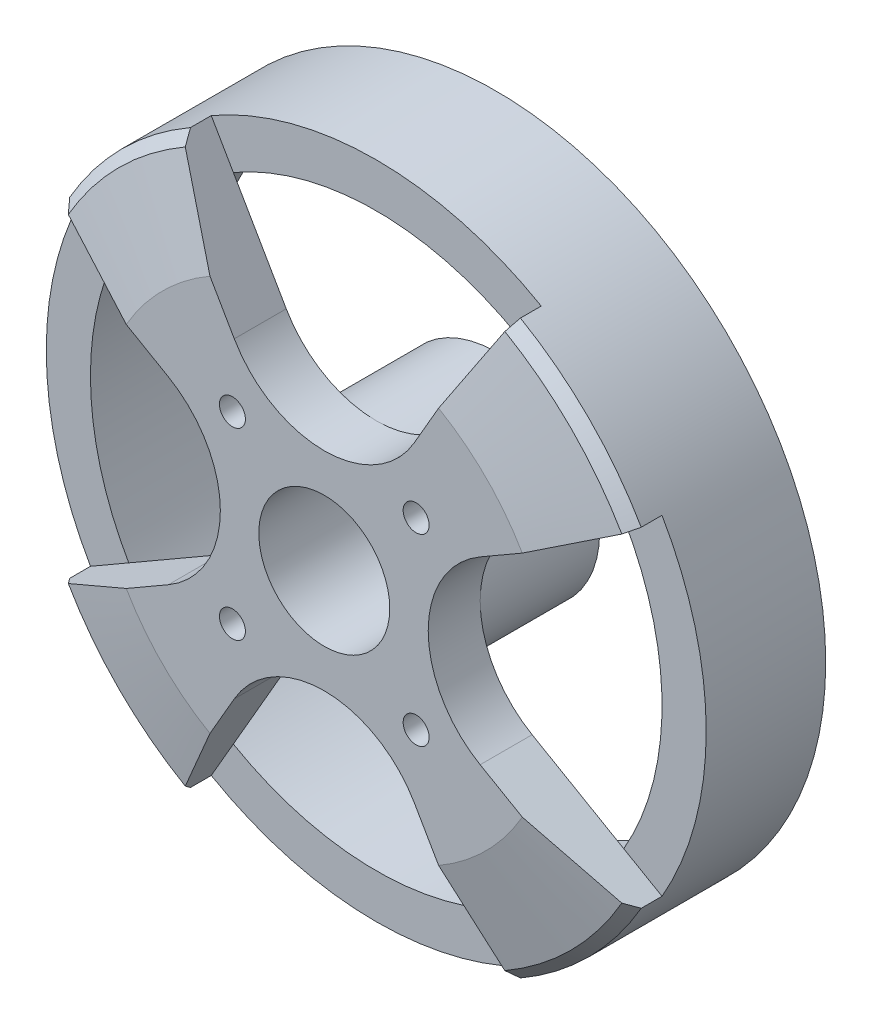
from build123d import *

# Parameters (mm, degrees)
SKETCH_1_R          = 31.75
EXTRUDE_1_DEPTH     = 14.5
CHAMFER_1_SIZE      = 1
SKETCH_3_R          = 30.75
SKETCH_2_R          = 22
SKETCH_4_R          = 6.3
CUT_EXTRUDE_1_DEPTH = 48.836962696
CUT_EXTRUDE_2_DEPTH = 5
SKETCH_6_R          = 27.5
CUT_EXTRUDE_3_DEPTH = 11.5
M3X0_51_D           = 2.5
SKETCH_11_R         = 10
SKETCH_11_R_2       = 6.3
EXTRUDE_2_DEPTH     = 11.5


with BuildPart() as part:
    # Эскиз1 → Бобышка-Вытянуть1 (new body)
    with BuildSketch(Plane.XY):
        with Locations(Location((0, 0, 0), (0, 0, 180))):
            Circle(SKETCH_1_R)
    extrude(amount=EXTRUDE_1_DEPTH)

    # Фаска1
    chamfer_1_edges = [part.edges().sort_by_distance(p)[0] for p in [
        (31.75, 0, 14.5),
    ]]
    chamfer(chamfer_1_edges, length=CHAMFER_1_SIZE)

    # Эскиз3 → По сечениям3 section 0
    with BuildSketch(Plane.XY.offset(14.5)):
        Circle(SKETCH_3_R)
    # Эскиз2 → По сечениям3 section 1
    with BuildSketch(Plane.XY.offset(16.5)):
        Circle(SKETCH_2_R)
    loft()

    # Эскиз4 → Вырез-Вытянуть1 (cut, through all)
    with BuildSketch(Plane.XY.offset(16.5)):
        Circle(SKETCH_4_R)
    extrude(amount=-CUT_EXTRUDE_1_DEPTH, mode=Mode.SUBTRACT)

    # Эскиз5 → Вырез-Вытянуть2 (cut)
    with BuildSketch(Plane.XY.offset(16.5)):
        with BuildLine():
            Line((-8.660254038, 15), (-15.875, 27.49630657))
            ThreePointArc((-15.875, 27.49630657), (0, 31.75), (15.875, 27.49630657))
            Line((15.875, 27.49630657), (8.660254038, 15))
            ThreePointArc((8.660254038, 15), (0, 10), (-8.660254038, 15))
        make_face()
        with BuildLine():
            Line((15, 8.660254038), (27.49630657, 15.875))
            ThreePointArc((27.49630657, 15.875), (31.75, 0), (27.49630657, -15.875))
            Line((27.49630657, -15.875), (15, -8.660254038))
            ThreePointArc((15, -8.660254038), (10, 0), (15, 8.660254038))
        make_face()
        with BuildLine():
            Line((8.660254038, -15), (15.875, -27.49630657))
            ThreePointArc((15.875, -27.49630657), (0, -31.75), (-15.875, -27.49630657))
            Line((-15.875, -27.49630657), (-8.660254038, -15))
            ThreePointArc((-8.660254038, -15), (0, -10), (8.660254038, -15))
        make_face()
        with BuildLine():
            Line((-15, -8.660254038), (-27.49630657, -15.875))
            ThreePointArc((-27.49630657, -15.875), (-31.75, 0), (-27.49630657, 15.875))
            Line((-27.49630657, 15.875), (-15, 8.660254038))
            ThreePointArc((-15, 8.660254038), (-10, 0), (-15, -8.660254038))
        make_face()
    extrude(amount=-CUT_EXTRUDE_2_DEPTH, mode=Mode.SUBTRACT)

    # Эскиз6 → Вырез-Вытянуть3 (cut)
    with BuildSketch(Plane(origin=(0, 0, 0), x_dir=(-1, 0, 0), z_dir=(0, 0, -1))):
        Circle(SKETCH_6_R)
    extrude(amount=-CUT_EXTRUDE_3_DEPTH, mode=Mode.SUBTRACT)

    # Отверстие обработанное метчиком M3x0.51 (through all)
    with Locations(Plane.XY.offset(16.5)):
        with Locations((-8.838834765, 8.838834765), (-8.838834765, -8.838834765), (8.838834765, -8.838834765), (8.838834765, 8.838834765)):
            Hole(M3X0_51_D / 2)

    # Эскиз11 → Бобышка-Вытянуть2 (add)
    with BuildSketch(Plane(origin=(0, 0, 11.5), x_dir=(-1, 0, 0), z_dir=(0, 0, -1))):
        with Locations(Location((0, 0, 0), (0, 0, 180))):
            Circle(SKETCH_11_R)
        with Locations(Location((0, 0, 0), (0, 0, 180))):
            Circle(SKETCH_11_R_2, mode=Mode.SUBTRACT)
    extrude(amount=EXTRUDE_2_DEPTH)


solid = part.part
